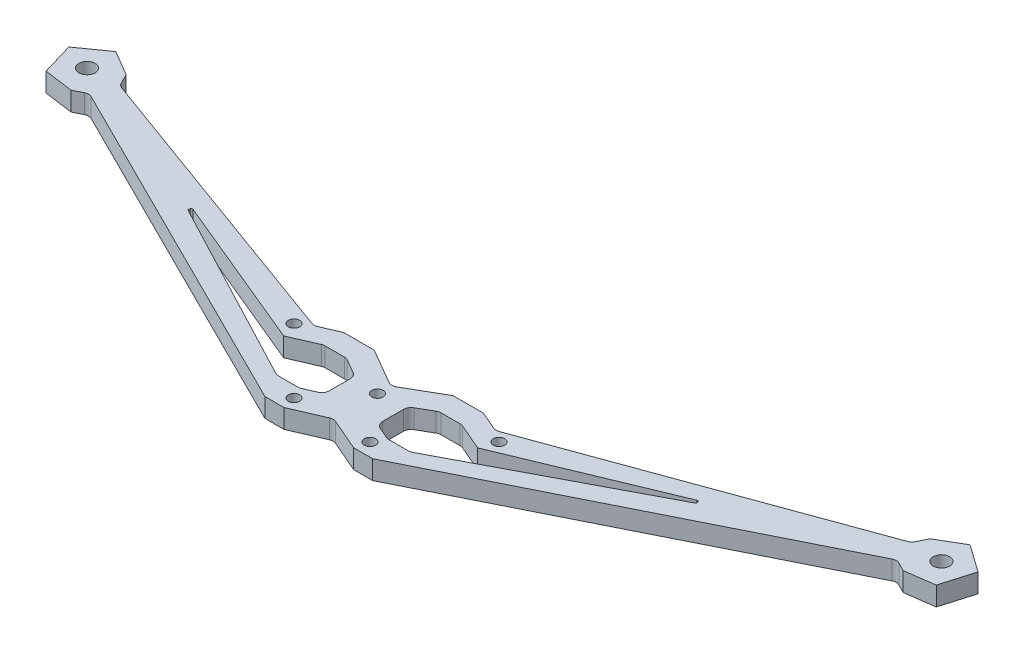
from build123d import *

# Parameters (mm, degrees)
EXTRUDE_1_DEPTH        = 5
EXTRUDE_2_DEPTH        = 5
SKETCH_5_R             = 2.15
CUT_EXTRUDE_3_DEPTH    = 3.5
CUT_EXTRUDE_4_DEPTH    = 5
SKETCH_8_R             = 1.5
CUT_EXTRUDE_5_DEPTH    = 5
FILLET_1_R             = 2
FILLET_2_R             = 0.4
FILLET_4_R             = 2
FILLET_1_OF_MIRROR_2_R = 2
FILLET_2_OF_MIRROR_2_R = 0.4
FILLET_4_OF_MIRROR_2_R = 2
FILLET_3_R             = 2
SKETCH_10_R            = 0.8
CUT_EXTRUDE_6_DEPTH    = 10


with BuildPart() as part:
    # 草图2 → 凸台-拉伸1 (new body)
    with BuildSketch(Plane(origin=(0, 0, 0), x_dir=(1, 0, 0), z_dir=(0, 1, 0))):
        Polygon((0, -7.5), (0, 7.5), (-10.392304845, 13.5), (-18.392304845, 13.5), (-23.898712869, 11.116835995), (-104.216362147, 40.350069618), (-106.3513241, 34.484309861), (-103.323886643, 32.974885226), (-14.177346707, -11.471940008), (-9.177346707, -11.471940008), align=None)
    extrude_1 = extrude(amount=EXTRUDE_1_DEPTH)

    # 草图4 → 凸台-拉伸2 (add)
    with BuildSketch(Plane(origin=(0, 0, 0), x_dir=(1, 0, 0), z_dir=(0, 1, 0))):
        Polygon((-105.836537935, 43.651722154), (-104.216362147, 40.350069618), (-106.3513241, 34.484309861), (-109.577310483, 32.862960495), (-117.227960723, 33.920942119), (-119.716156877, 42.421286113), (-112.5, 47.556853078), align=None)
    extrude_2 = extrude(amount=EXTRUDE_2_DEPTH)

    # 草图5 → 切除-拉伸3 (cut)
    with BuildSketch(Plane(origin=(0, 5, 0), x_dir=(1, 0, 0), z_dir=(0, 1, 0))):
        with Locations((-112.5, 40)):
            Circle(SKETCH_5_R)
    cut_extrude_3 = extrude(amount=-CUT_EXTRUDE_3_DEPTH, mode=Mode.SUBTRACT)

    # 草图6 → 切除-拉伸4 (cut)
    with BuildSketch(Plane(origin=(0, 5, 0), x_dir=(1, 0, 0), z_dir=(0, 1, 0))):
        Polygon((-25.538029788, 4.822447994), (-66.670701963, 21.893639642), (-67.092623285, 21.03753444), (-17.588673353, -4.985970004), (-11.588673353, -4.985970004), (-7, -3), (-7, 0), (-7, 5), (-12.196152423, 8), (-18.196152423, 8), align=None)
    cut_extrude_4 = extrude(amount=-CUT_EXTRUDE_4_DEPTH, mode=Mode.SUBTRACT)

    # 草图8 → 切除-拉伸5 (cut)
    with BuildSketch(Plane(origin=(0, 5, 0), x_dir=(1, 0, 0), z_dir=(0, 1, 0))):
        with Locations((0, 4)):
            Circle(SKETCH_8_R)
        with Locations((-10, -8)):
            Circle(SKETCH_8_R)
        with Locations((-27, 9)):
            Circle(SKETCH_8_R)
    cut_extrude_5 = extrude(amount=-CUT_EXTRUDE_5_DEPTH, mode=Mode.SUBTRACT)

    # 圆角1
    fillet_1_edges = [part.edges().sort_by_distance(p)[0] for p in [
        (-23.898712869, 2.5, -11.116835995),
        (-18.196152423, 2.5, -8),
        (-12.196152423, 2.5, -8),
        (-7, 2.5, -5),
        (-7, 2.5, 3),
        (-11.588673353, 2.5, 4.985970004),
        (-17.588673353, 2.5, 4.985970004),
    ]]
    fillet(fillet_1_edges, radius=FILLET_1_R)

    # 圆角2
    fillet_2_edges = [part.edges().sort_by_distance(p)[0] for p in [
        (-67.092623285, 2.5, -21.03753444),
        (-66.670701963, 2.5, -21.893639642),
    ]]
    fillet(fillet_2_edges, radius=FILLET_2_R)

    # 圆角4
    fillet_4_edges = [part.edges().sort_by_distance(p)[0] for p in [
        (-106.3513241, 2.5, -34.484309861),
        (-104.216362147, 2.5, -40.350069618),
    ]]
    fillet(fillet_4_edges, radius=FILLET_4_R)

    # 镜向2: 凸台-拉伸1, 凸台-拉伸2, 切除-拉伸3, 切除-拉伸4, 切除-拉伸5 across Right Plane
    add(extrude_1.mirror(Plane(origin=(0, 0, 0), x_dir=(0, 0, -1), z_dir=(1, 0, 0))))
    add(extrude_2.mirror(Plane(origin=(0, 0, 0), x_dir=(0, 0, -1), z_dir=(1, 0, 0))))
    add(cut_extrude_3.mirror(Plane(origin=(0, 0, 0), x_dir=(0, 0, -1), z_dir=(1, 0, 0))), mode=Mode.SUBTRACT)
    add(cut_extrude_4.mirror(Plane(origin=(0, 0, 0), x_dir=(0, 0, -1), z_dir=(1, 0, 0))), mode=Mode.SUBTRACT)
    add(cut_extrude_5.mirror(Plane(origin=(0, 0, 0), x_dir=(0, 0, -1), z_dir=(1, 0, 0))), mode=Mode.SUBTRACT)

    # 圆角1 of 镜向2
    fillet_1_of_mirror_2_edges = [part.edges().sort_by_distance(p)[0] for p in [
        (23.898712869, 2.5, -11.116835995),
        (18.196152423, 2.5, -8),
        (12.196152423, 2.5, -8),
        (7, 2.5, -5),
        (7, 2.5, 3),
        (11.588673353, 2.5, 4.985970004),
        (17.588673353, 2.5, 4.985970004),
    ]]
    fillet(fillet_1_of_mirror_2_edges, radius=FILLET_1_OF_MIRROR_2_R)

    # 圆角2 of 镜向2
    fillet_2_of_mirror_2_edges = [part.edges().sort_by_distance(p)[0] for p in [
        (67.092623285, 2.5, -21.03753444),
        (66.670701963, 2.5, -21.893639642),
    ]]
    fillet(fillet_2_of_mirror_2_edges, radius=FILLET_2_OF_MIRROR_2_R)

    # 圆角4 of 镜向2
    fillet_4_of_mirror_2_edges = [part.edges().sort_by_distance(p)[0] for p in [
        (106.3513241, 2.5, -34.484309861),
        (104.216362147, 2.5, -40.350069618),
    ]]
    fillet(fillet_4_of_mirror_2_edges, radius=FILLET_4_OF_MIRROR_2_R)

    # 圆角3
    fillet_3_edges = [part.edges().sort_by_distance(p)[0] for p in [
        (0, 2.5, -7.5),
        (0, 2.5, 7.5),
    ]]
    fillet(fillet_3_edges, radius=FILLET_3_R)

    # 草图10 → 切除-拉伸6 (cut)
    with BuildSketch(Plane(origin=(0, 1.5, 0), x_dir=(1, 0, 0), z_dir=(0, 1, 0))):
        with Locations((-112.5, 40)):
            Circle(SKETCH_10_R)
        with Locations((112.5, 40)):
            Circle(SKETCH_10_R)
    extrude(amount=-CUT_EXTRUDE_6_DEPTH, mode=Mode.SUBTRACT)


solid = part.part
